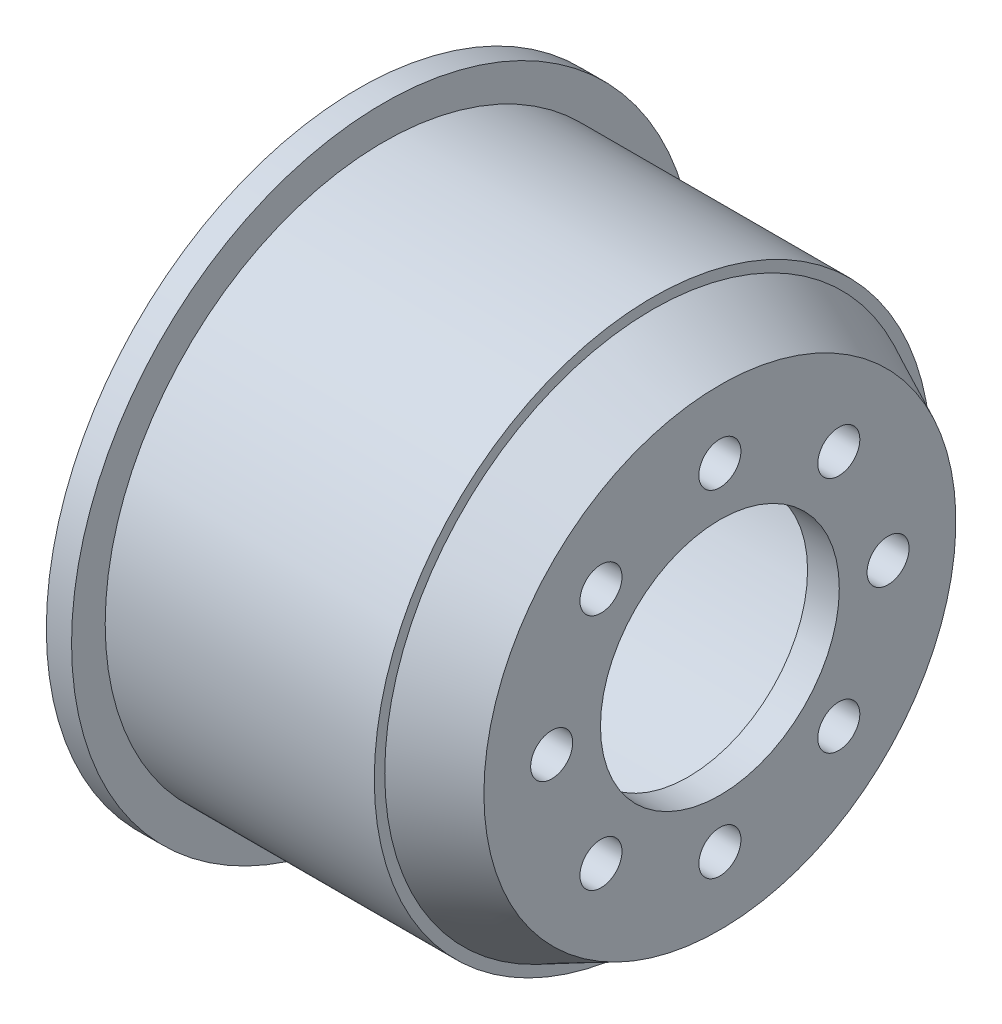
from build123d import *

# Parameters (mm, degrees)
SKETCH2_R          = 1.25
CUT_EXTRUDE1_DEPTH = 5


with BuildPart() as part:
    # Sketch1 → Revolve1 (revolve)
    with BuildSketch(Plane(origin=(0, 0, 0), x_dir=(1, 0, 0), z_dir=(0, 1, 0))):
        Polygon((8.936305636, 8.625), (8.936305636, 14.031614125), (4.936305636, 15.92728698), (4.936305636, 16.55), (-11.063694364, 16.55), (-11.063694364, 18.55), (-12.563694364, 18.55), (-12.563694364, 16.55), (-12.563694364, 14.55), (3.172405145, 14.55), (7.050606918, 12.712049543), (7.050606918, 7.1), (8.936305636, 7.1), align=None)
    revolve(axis=Axis((-37.278866169, 0, 0), (1, 0, 0)))

    # Sketch2 → Cut-Extrude1 (cut)
    with BuildSketch(Plane(origin=(8.936305636, 0, 0), x_dir=(0, 0, -1), z_dir=(1, 0, 0))):
        with Locations((0, 10)):
            Circle(SKETCH2_R)
        with Locations((7.071067812, 7.071067812)):
            Circle(SKETCH2_R)
        with Locations((10, 0)):
            Circle(SKETCH2_R)
        with Locations((7.071067812, -7.071067812)):
            Circle(SKETCH2_R)
        with Locations((0, -10)):
            Circle(SKETCH2_R)
        with Locations((-7.071067812, -7.071067812)):
            Circle(SKETCH2_R)
        with Locations((-10, 0)):
            Circle(SKETCH2_R)
        with Locations((-7.071067812, 7.071067812)):
            Circle(SKETCH2_R)
    extrude(amount=-CUT_EXTRUDE1_DEPTH, mode=Mode.SUBTRACT)


solid = part.part
